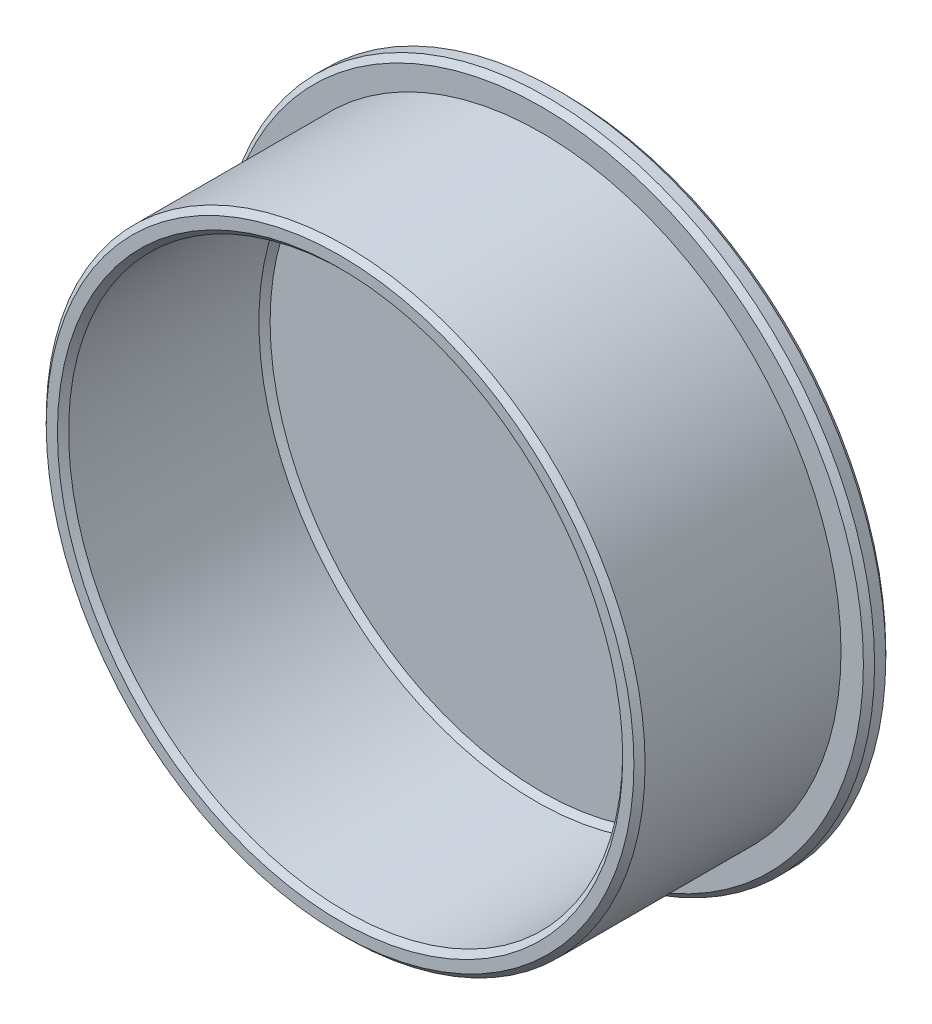
from build123d import *

# Parameters (mm, degrees)
SKETCH2_R           = 26.75
SKETCH2_R_2         = 29.25
SKETCH2_R_3         = 24.75
BOSS_EXTRUDE1_DEPTH = 2
SKETCH2_3_R         = 26.75
SKETCH2_3_R_2       = 24.75
BOSS_EXTRUDE2_DEPTH = 20
CHAMFER1_SIZE       = 0.5


with BuildPart() as part:
    # Sketch2 → Boss-Extrude1 (new body)
    with BuildSketch(Plane.XY):
        Circle(SKETCH2_R)
        Circle(SKETCH2_R_2)
        Circle(SKETCH2_R, mode=Mode.SUBTRACT)
        Circle(SKETCH2_R_3)
    extrude(amount=BOSS_EXTRUDE1_DEPTH)

    # Sketch2_3 → Boss-Extrude2 (add)
    with BuildSketch(Plane.XY):
        Circle(SKETCH2_3_R)
        Circle(SKETCH2_3_R_2, mode=Mode.SUBTRACT)
    extrude(amount=BOSS_EXTRUDE2_DEPTH)

    # Chamfer1
    chamfer1_edges = [part.edges().sort_by_distance(p)[0] for p in [
        (-26.75, 0, 20),
        (-29.25, 0, 0),
        (-29.25, 0, 2),
        (-24.75, 0, 2),
        (-24.75, 0, 20),
    ]]
    chamfer(chamfer1_edges, length=CHAMFER1_SIZE)


solid = part.part
